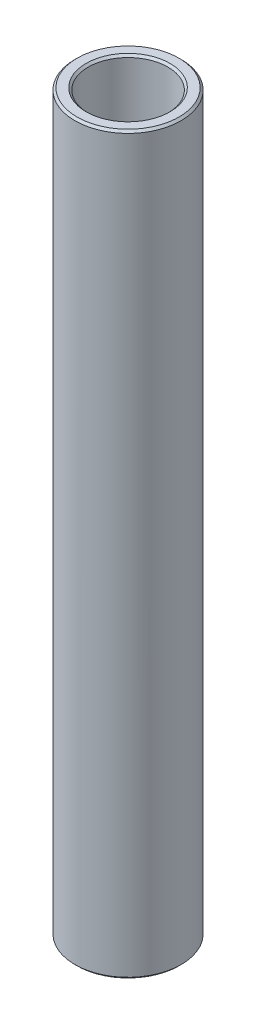
from build123d import *

# Parameters (mm, degrees)
SKETCH1_W     = 1.5875
SKETCH1_H     = 87.864991064
CHAMFER1_SIZE = 0.254


with BuildPart() as part:
    # Sketch1 → Revolve1 (revolve)
    with BuildSketch(Plane.XY):
        with Locations((5.55625, 114.576190497)):
            Rectangle(SKETCH1_W, SKETCH1_H)
    revolve(axis=Axis((0, 61.118694965, 0), (0, 1, 0)))

    # Chamfer1
    chamfer1_edges = [part.edges().sort_by_distance(p)[0] for p in [
        (-6.35, 70.643694964, 0),
        (-6.350000002, 158.508686029, 0),
        (-4.762500002, 158.508686029, 0),
        (-4.7625, 70.643694965, 0),
    ]]
    chamfer(chamfer1_edges, length=CHAMFER1_SIZE)


solid = part.part
